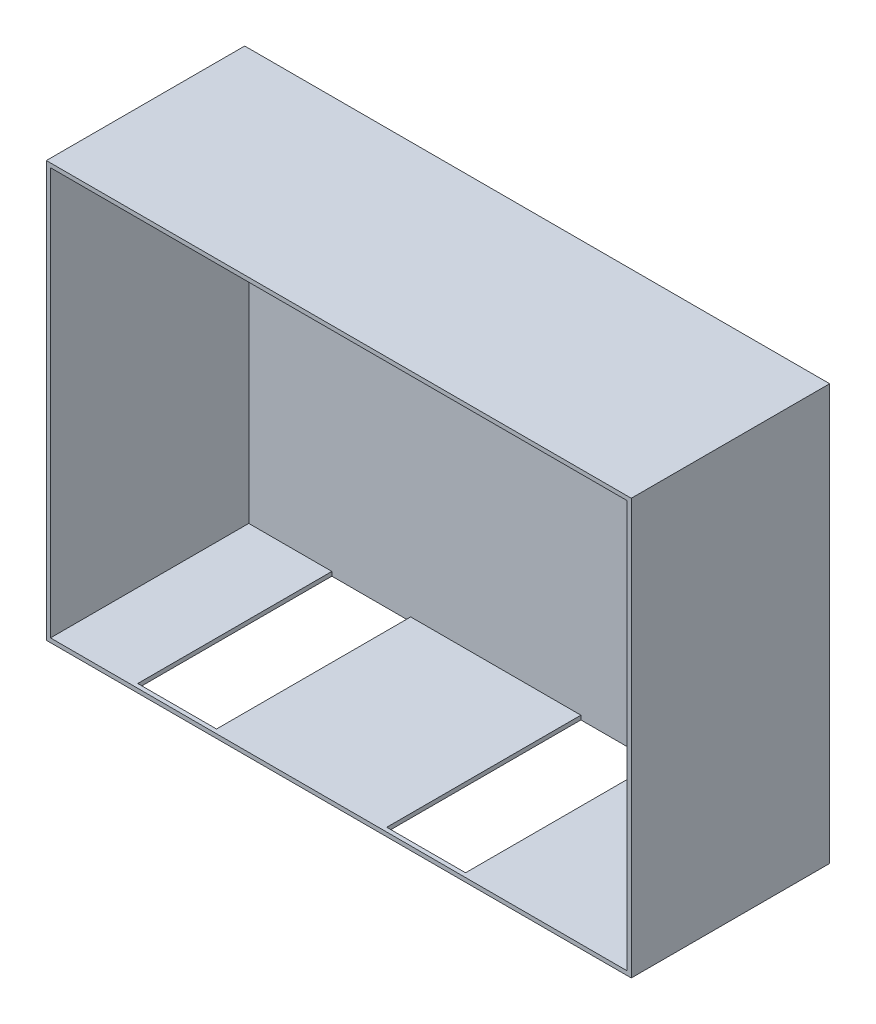
from build123d import *

# Parameters (mm, degrees)
CROQUIS1_W              = 7080
CROQUIS1_H              = 5029
CROQUIS1_W_2            = 6980
CROQUIS1_H_2            = 4929
SALIENTE_EXTRUIR1_DEPTH = 2400
CORTAR_EXTRUIR1_REACH   = 5031
CROQUIS2_W              = 954
CROQUIS2_H              = 2350
CROQUIS3_W              = 7080
CROQUIS3_H              = 5029
SALIENTE_EXTRUIR2_DEPTH = 1
CORTAR_EXTRUIR2_REACH   = 3
CROQUIS4_R              = 10


with BuildPart() as part:
    # Croquis1 → Saliente-Extruir1 (new body)
    with BuildSketch(Plane.XY):
        Rectangle(CROQUIS1_W, CROQUIS1_H)
        Rectangle(CROQUIS1_W_2, CROQUIS1_H_2, mode=Mode.SUBTRACT)
    extrude(amount=SALIENTE_EXTRUIR1_DEPTH)

    # Croquis2 → Cortar-Extruir1 (cut, up to next)
    with BuildSketch(Plane.XZ.offset(2514.5), mode=Mode.PRIVATE) as cortar_extruir1_sk1:
        with Locations((-2007, 1175)):
            Rectangle(CROQUIS2_W, CROQUIS2_H)
    cortar_extruir1_tool1 = extrude(cortar_extruir1_sk1.sketch, amount=-CORTAR_EXTRUIR1_REACH, mode=Mode.PRIVATE) & part.part
    add(cortar_extruir1_tool1.solids().sort_by_distance((-2007, -2514.5, 1175))[0], mode=Mode.SUBTRACT)
    # Croquis2 → Cortar-Extruir1 (cut, up to next)
    with BuildSketch(Plane.XZ.offset(2514.5), mode=Mode.PRIVATE) as cortar_extruir1_sk2:
        with Locations((1007, 1175)):
            Rectangle(CROQUIS2_W, CROQUIS2_H)
    cortar_extruir1_tool2 = extrude(cortar_extruir1_sk2.sketch, amount=-CORTAR_EXTRUIR1_REACH, mode=Mode.PRIVATE) & part.part
    add(cortar_extruir1_tool2.solids().sort_by_distance((1007, -2514.5, 1175))[0], mode=Mode.SUBTRACT)

    # Croquis3 → Saliente-Extruir2 (add)
    with BuildSketch(Plane(origin=(0, 0, 0), x_dir=(-1, 0, 0), z_dir=(0, 0, -1))):
        Rectangle(CROQUIS3_W, CROQUIS3_H)
    extrude(amount=SALIENTE_EXTRUIR2_DEPTH)

    # Croquis4 → Cortar-Extruir2 (cut, up to next)
    with BuildSketch(Plane.XY, mode=Mode.PRIVATE) as cortar_extruir2_sk1:
        with Locations((-1986, 489.5)):
            Circle(CROQUIS4_R)
    cortar_extruir2_tool1 = extrude(cortar_extruir2_sk1.sketch, amount=-CORTAR_EXTRUIR2_REACH, mode=Mode.PRIVATE) & part.part
    add(cortar_extruir2_tool1.solids().sort_by_distance((-1986, 489.5, 0))[0], mode=Mode.SUBTRACT)


solid = part.part
